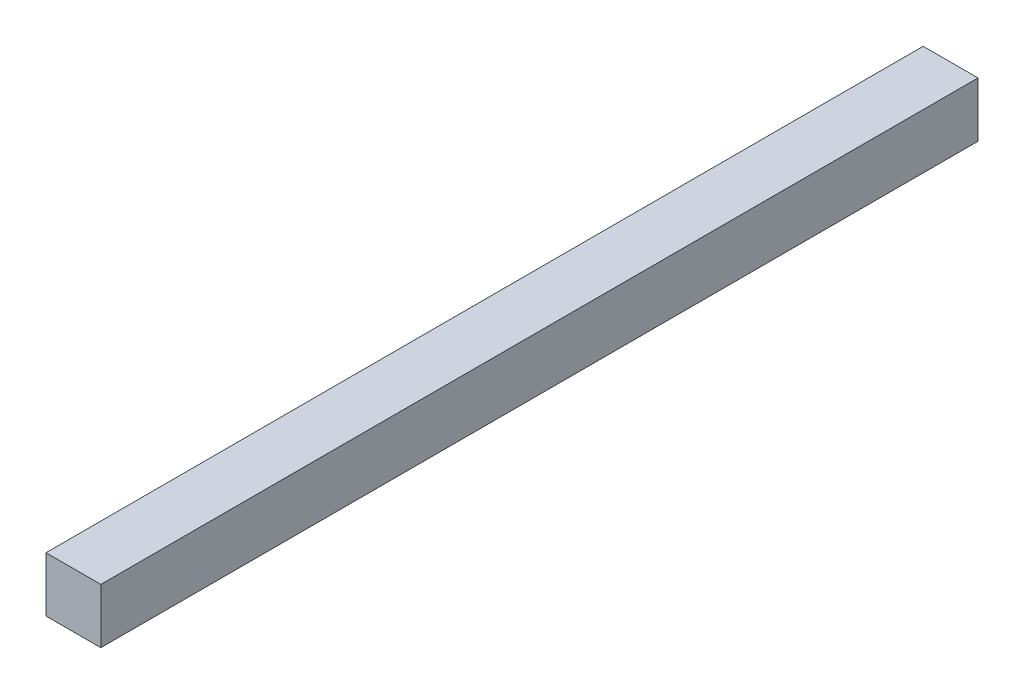
from build123d import *

# Parameters (mm, degrees)
SKETCH1_W           = 10
SKETCH1_H           = 10
BOSS_EXTRUDE1_DEPTH = 160


with BuildPart() as part:
    # Sketch1 → Boss-Extrude1 (new body)
    with BuildSketch(Plane.XY):
        with Locations((-60.770360526, 25.236867054)):
            Rectangle(SKETCH1_W, SKETCH1_H)
    extrude(amount=BOSS_EXTRUDE1_DEPTH)


solid = part.part
